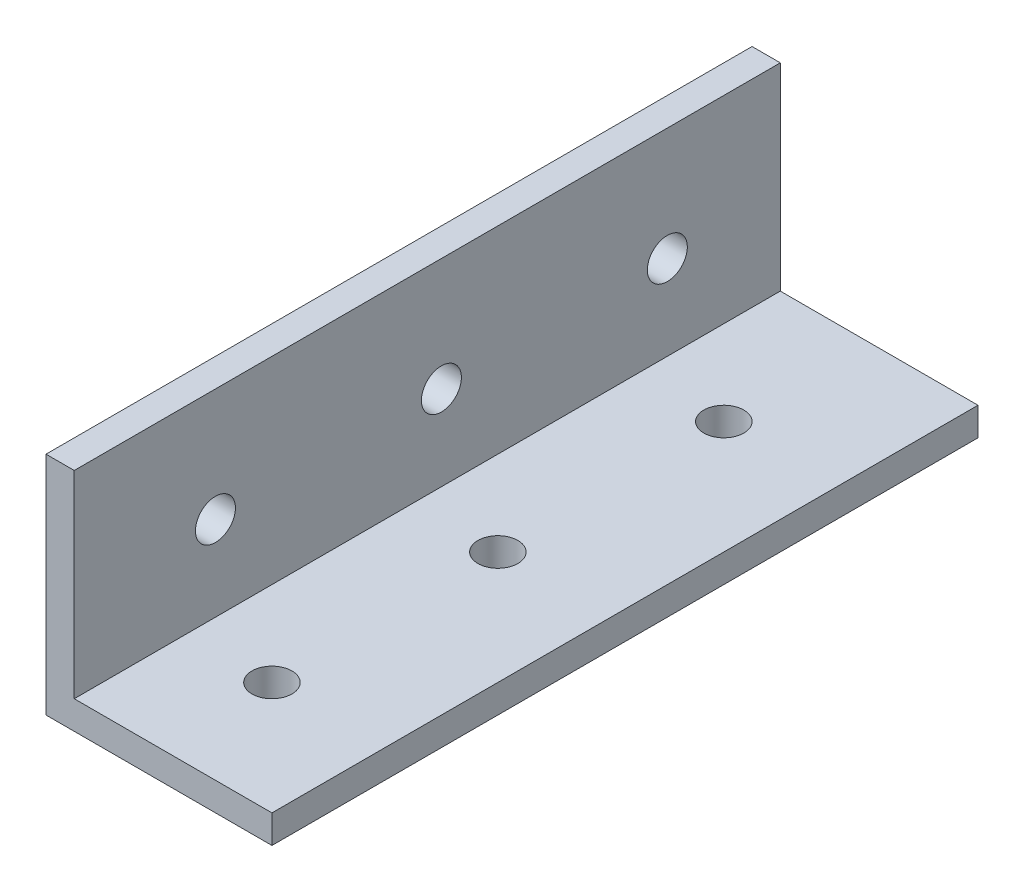
from build123d import *

# Parameters (mm, degrees)
BOSS_EXTRUDE1_DEPTH   = 79.375
F_8_CLEARANCE_HOLE1_D = 4.4958
F_8_CLEARANCE_HOLE2_D = 4.4958


with BuildPart() as part:
    # Sketch1 → Boss-Extrude1 (new body)
    with BuildSketch(Plane.XY):
        Polygon((0, 0), (25.4, 0), (25.4, 3.175), (3.175, 3.175), (3.175, 25.4), (0, 25.4), align=None)
    extrude(amount=BOSS_EXTRUDE1_DEPTH)

    # #8 Clearance Hole1 (through all)
    with Locations(Plane.XZ):
        with Locations((12.7, 66.675), (12.7, 41.275), (12.7, 15.875)):
            Hole(F_8_CLEARANCE_HOLE1_D / 2)

    # #8 Clearance Hole2 (through all)
    with Locations(Plane.ZY):
        with Locations((63.5, 12.7), (38.1, 12.7), (12.7, 12.7)):
            Hole(F_8_CLEARANCE_HOLE2_D / 2)


solid = part.part
